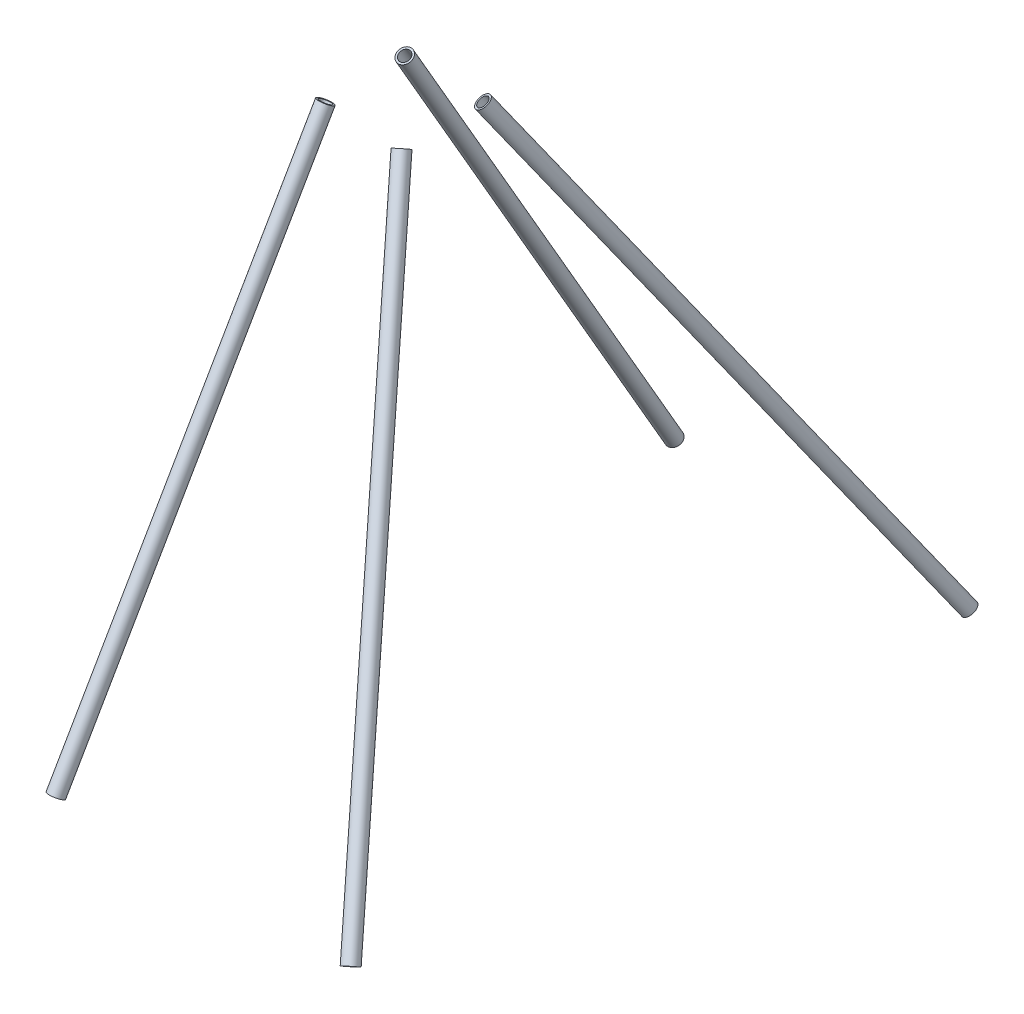
from build123d import *

# Parameters (mm, degrees)
BOSS_EXTRUDE1_START = -4.7625
SKETCH4_R           = 6.35
SKETCH4_R_2         = 4.699
BOSS_EXTRUDE1_DEPTH = 460.375
BOSS_EXTRUDE2_START = 4.7625
SKETCH5_R           = 6.35
SKETCH5_R_2         = 4.699
BOSS_EXTRUDE2_DEPTH = 495.3


with BuildPart() as part:
    # Sketch4 → Boss-Extrude1 (new body)
    with BuildSketch(Plane(origin=(0, -406.4, 266.7), x_dir=(-1, 0, 0), z_dir=(0, -0.865734831, 0.500502949)).offset(BOSS_EXTRUDE1_START)):
        Circle(SKETCH4_R)
        Circle(SKETCH4_R_2, mode=Mode.SUBTRACT)
    extrude(amount=-BOSS_EXTRUDE1_DEPTH)


with BuildPart() as body_2:
    # Sketch5 → Boss-Extrude2 (new body)
    with BuildSketch(Plane(origin=(254, -406.4, 266.7), x_dir=(0.926607645, 0.325541936, -0.188203932), z_dir=(-0.376029616, 0.802196513, -0.463769859)).offset(BOSS_EXTRUDE2_START)):
        Circle(SKETCH5_R)
        Circle(SKETCH5_R_2, mode=Mode.SUBTRACT)
    extrude(amount=BOSS_EXTRUDE2_DEPTH)


with BuildPart() as body_3:
    # Mirror1: mirrored copy
    add(part.part.mirror(Plane.XY))


with BuildPart() as body_4:
    # Mirror1 2: mirrored copy
    add(body_2.part.mirror(Plane.XY))


solid = Compound([part.part, body_2.part, body_3.part, body_4.part])
